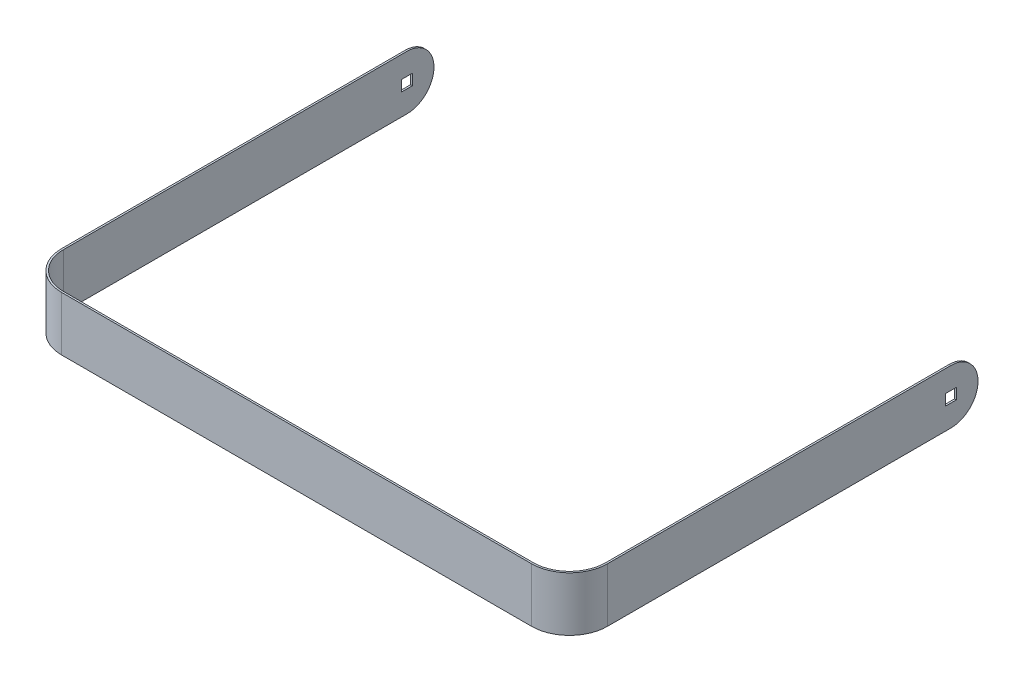
from build123d import *

# Parameters (mm, degrees)
LINEAR_AUSTRAGEN_D_NN1_DEPTH    = 30
SCHNITT_LINEAR_AUSTRAGEN1_DEPTH = 303
SKIZZE5_W                       = 6
SKIZZE5_H                       = 6
SCHNITT_LINEAR_AUSTRAGEN2_DEPTH = 303


with BuildPart() as part:
    # Skizze3 → Linear-Austragen-Dünn1 (new body)
    with BuildSketch(Plane.XZ):
        with BuildLine():
            Line((-151, -226), (-151, -151))
            Line((-151, -151), (-151, -21))
            ThreePointArc((-151, -21), (-144.849242405, -6.150757595), (-130, 0))
            Line((-130, 0), (130, 0))
            ThreePointArc((130, 0), (144.849242405, -6.150757595), (151, -21))
            Line((151, -21), (151, -151))
            Line((151, -151), (151, -226))
            Line((151, -226), (150, -226))
            Line((150, -226), (150, -151))
            Line((150, -151), (150, -21))
            ThreePointArc((150, -21), (144.142135624, -6.857864376), (130, -1))
            Line((130, -1), (-130, -1))
            ThreePointArc((-130, -1), (-144.142135624, -6.857864376), (-150, -21))
            Line((-150, -21), (-150, -151))
            Line((-150, -151), (-150, -226))
            Line((-150, -226), (-151, -226))
        make_face()
    extrude(amount=LINEAR_AUSTRAGEN_D_NN1_DEPTH)

    # Skizze4 → Schnitt-Linear austragen1 (cut, through all)
    with BuildSketch(Plane(origin=(151, 0, 0), x_dir=(0, 0, -1), z_dir=(1, 0, 0))):
        with BuildLine():
            Line((236.953367606, 0), (211, 0))
            ThreePointArc((211, 0), (226, -15), (211, -30))
            Line((211, -30), (236.953367606, -30))
            Line((236.953367606, -30), (236.953367606, 0))
        make_face()
    extrude(amount=-SCHNITT_LINEAR_AUSTRAGEN1_DEPTH, mode=Mode.SUBTRACT)

    # Skizze5 → Schnitt-Linear austragen2 (cut, through all)
    with BuildSketch(Plane(origin=(151, 0, 0), x_dir=(0, 0, -1), z_dir=(1, 0, 0))):
        with Locations((211, -15)):
            Rectangle(SKIZZE5_W, SKIZZE5_H)
    extrude(amount=-SCHNITT_LINEAR_AUSTRAGEN2_DEPTH, mode=Mode.SUBTRACT)


solid = part.part
